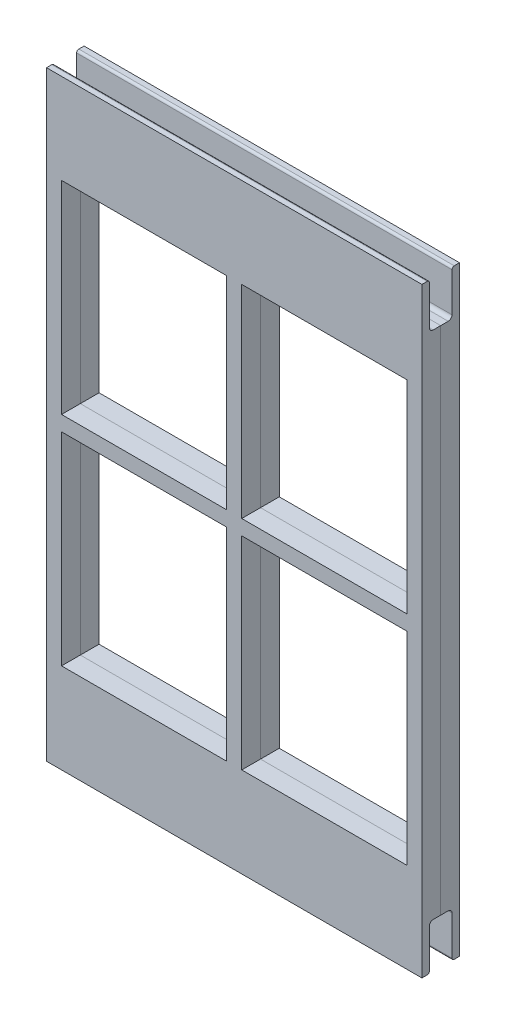
from build123d import *

# Parameters (mm, degrees)
ESBO_O1_W                  = 50
ESBO_O1_H                  = 10
ESBO_O1_W_2                = 22
ESBO_O1_H_2                = 1
RESSALTO_EXTRUS_O1_DEPTH   = 5
ESBO_O2_W                  = 1.5
ESBO_O2_H                  = 6
CORTE_EXTRUS_O2_DEPTH      = 54.162744802
CORTE_EXTRUS_O2_DEPTH_BACK = 54.162744802
FILETE3_R                  = 0.5
FILETE4_R                  = 0.3
DIVIDIR1_SURFACE_1_BACK    = 95.472
DIVIDIR1_SURFACE_1_DEPTH   = 190.944
DIVIDIR1_SURFACE_2_BACK    = 95.472
DIVIDIR1_SURFACE_2_DEPTH   = 190.944


with BuildPart() as part:
    # Esboço1 → Ressalto-extrusão1 (new body)
    with BuildSketch(Plane.XY):
        Polygon((-15.962962963, 32.12962963), (-17.962962963, 32.12962963), (-17.962962963, 30.132116639), (-17.962962963, 3.12962963), (-17.962962963, 1.12962963), (-17.962962963, -25.87037037), (-17.962962963, -27.87037037), (-15.962962963, -27.87037037), (6.037037037, -27.87037037), (8.037037037, -27.87037037), (30.037037037, -27.87037037), (32.037037037, -27.87037037), (32.037037037, -25.87037037), (32.037037037, 1.12962963), (32.037037037, 3.12962963), (32.037037037, 30.132116639), (32.037037037, 32.12962963), (30.037037037, 32.12962963), (8.037037037, 32.12962963), (6.037037037, 32.12962963), align=None)
        Polygon((6.037037037, 30.132116639), (7.037037037, 30.132116639), (8.037037037, 30.132116639), (30.037037037, 30.132116639), (30.037037037, 3.12962963), (30.037037037, 2.12962963), (30.037037037, 1.12962963), (30.037037037, -25.87037037), (8.037037037, -25.87037037), (7.037037037, -25.87037037), (6.037037037, -25.87037037), (-15.962962963, -25.87037037), (-15.962962963, 1.12962963), (-15.962962963, 2.12962963), (-15.962962963, 3.12962963), (-15.962962963, 30.132116639), align=None, mode=Mode.SUBTRACT)
        with Locations((7.037037037, -32.87037037)):
            Rectangle(ESBO_O1_W, ESBO_O1_H)
        Polygon((8.037037037, 30.132116639), (7.037037037, 30.132116639), (7.037037037, -25.87037037), (8.037037037, -25.87037037), (8.037037037, 1.12962963), (8.037037037, 2.12962963), (8.037037037, 3.12962963), align=None)
        Polygon((7.037037037, -25.87037037), (7.037037037, 30.132116639), (6.037037037, 30.132116639), (6.037037037, 3.12962963), (6.037037037, 2.12962963), (6.037037037, 1.12962963), (6.037037037, -25.87037037), align=None)
        with Locations((19.037037037, 2.62962963)):
            Rectangle(ESBO_O1_W_2, ESBO_O1_H_2)
        with Locations((19.037037037, 1.62962963)):
            Rectangle(ESBO_O1_W_2, ESBO_O1_H_2)
        with Locations((-4.962962963, 2.62962963)):
            Rectangle(ESBO_O1_W_2, ESBO_O1_H_2)
        with Locations((-4.962962963, 1.62962963)):
            Rectangle(ESBO_O1_W_2, ESBO_O1_H_2)
        with Locations((7.037037037, 37.12962963)):
            Rectangle(ESBO_O1_W, ESBO_O1_H)
    extrude(amount=RESSALTO_EXTRUS_O1_DEPTH)

    # Esboço2 → Corte-extrusão2 (cut, two sides)
    with BuildSketch(Plane(origin=(0, 0, 0), x_dir=(0, 0, -1), z_dir=(1, 0, 0))) as corte_extrus_o2_sk:
        with Locations((-3.25, -34.87037037)):
            Rectangle(ESBO_O2_W, ESBO_O2_H)
        with Locations((-1.75, -34.87037037)):
            Rectangle(ESBO_O2_W, ESBO_O2_H)
        with Locations((-3.25, 39.12962963)):
            Rectangle(ESBO_O2_W, ESBO_O2_H)
        with Locations((-1.75, 39.12962963)):
            Rectangle(ESBO_O2_W, ESBO_O2_H)
    extrude(amount=CORTE_EXTRUS_O2_DEPTH, mode=Mode.SUBTRACT)
    extrude(corte_extrus_o2_sk.sketch, amount=-CORTE_EXTRUS_O2_DEPTH_BACK, mode=Mode.SUBTRACT)

    # Filete3
    filete3_edges = [part.edges().sort_by_distance(p)[0] for p in [
        (7.037037037, -31.87037037, 4),
        (7.037037037, -31.87037037, 1),
        (7.037037037, 36.12962963, 1),
        (7.037037037, 36.12962963, 4),
    ]]
    fillet(filete3_edges, radius=FILETE3_R)

    # Filete4
    filete4_edges = [part.edges().sort_by_distance(p)[0] for p in [
        (7.037037037, -37.87037037, 1),
        (7.037037037, -37.87037037, 4),
        (7.037037037, 42.12962963, 4),
        (7.037037037, 42.12962963, 1),
    ]]
    fillet(filete4_edges, radius=FILETE4_R)


with BuildPart() as body_2:
    # Dividir1: the piece behind the surface
    add(part.part)
    # Dividir1 surface: a surface, the sketch's curves swept straight by 190.944 mm
    with BuildLine(Plane(origin=(0, 0, 0), x_dir=(1, 0, 0), z_dir=(0, 1, 0)).offset(-DIVIDIR1_SURFACE_1_BACK), mode=Mode.PRIVATE) as dividir1_surface_1_path:
        Line((-17.962962963, -2.5), (32.037037037, -2.5))
    dividir1_surface_1 = Shell.extrude(dividir1_surface_1_path.wire(), (0 * DIVIDIR1_SURFACE_1_DEPTH, 1 * DIVIDIR1_SURFACE_1_DEPTH, 0 * DIVIDIR1_SURFACE_1_DEPTH))
    split(bisect_by=dividir1_surface_1, keep=Keep.BOTTOM)


with BuildPart() as part_1:
    add(part.part)

    # Dividir1: split by a surface, the side it looks to stays
    # Dividir1 surface: a surface, the sketch's curves swept straight by 190.944 mm
    with BuildLine(Plane(origin=(0, 0, 0), x_dir=(1, 0, 0), z_dir=(0, 1, 0)).offset(-DIVIDIR1_SURFACE_2_BACK), mode=Mode.PRIVATE) as dividir1_surface_2_path:
        Line((-17.962962963, -2.5), (32.037037037, -2.5))
    dividir1_surface_2 = Shell.extrude(dividir1_surface_2_path.wire(), (0 * DIVIDIR1_SURFACE_2_DEPTH, 1 * DIVIDIR1_SURFACE_2_DEPTH, 0 * DIVIDIR1_SURFACE_2_DEPTH))
    split(bisect_by=dividir1_surface_2, keep=Keep.TOP)


solid = Compound([body_2.part, part_1.part])
